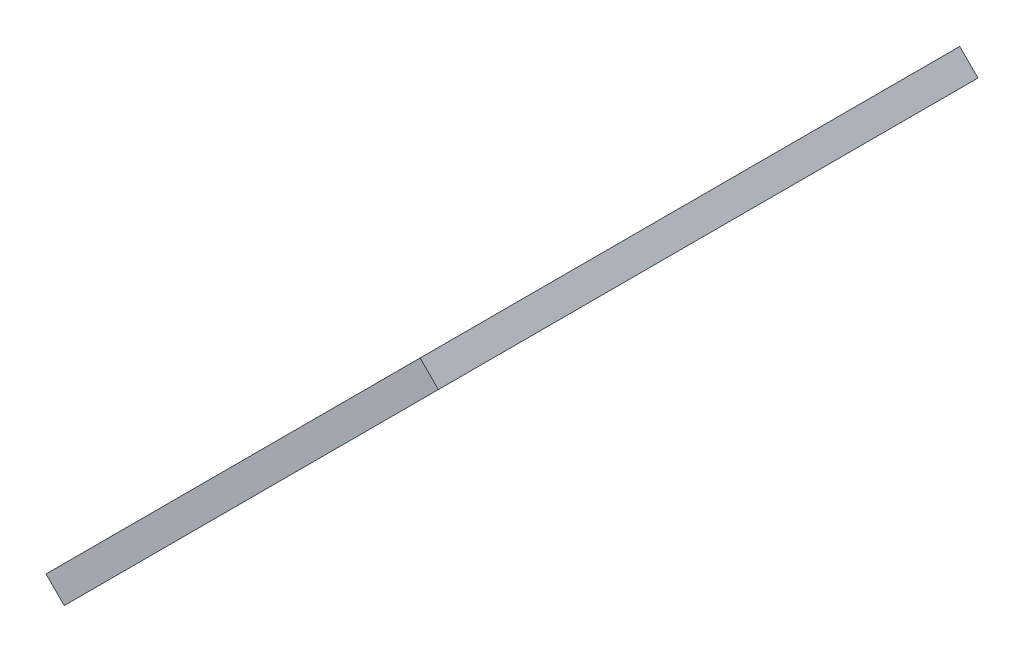
from build123d import *

# Parameters (mm, degrees)
BOSS_EXTRUDE2_DEPTH = 1.5


with BuildPart() as part:
    # Sketch2 → Boss-Extrude2 (new body, symmetric)
    with BuildSketch(Plane(origin=(80.401490288, -80.401490288, 0), x_dir=(-0.707106781, -0.707106781, 0), z_dir=(0.707106781, -0.707106781, 0))):
        Polygon((49.638102576, -111.164878), (111.164878, -111.164878), (111.164878, -4.906903198), (49.638102576, -48.412903325), align=None)
    extrude(amount=BOSS_EXTRUDE2_DEPTH, both=True)


solid = part.part
